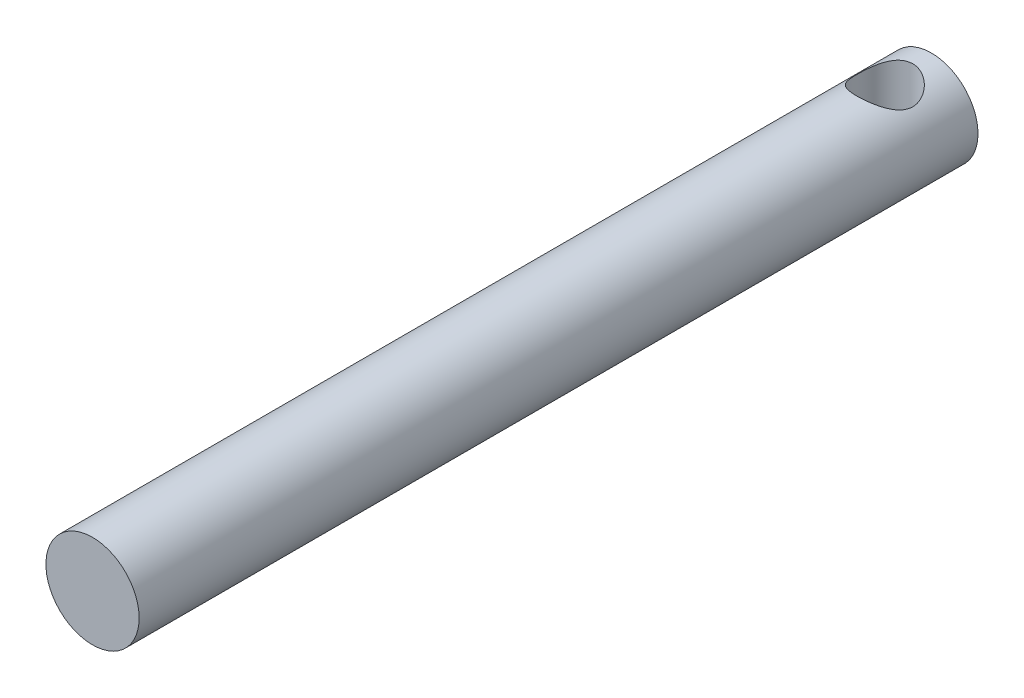
from build123d import *

# Parameters (mm, degrees)
SKETCH_1_R          = 10
EXTRUDE_1_DEPTH     = 180
SKETCH_2_R          = 6
CUT_EXTRUDE_2_DEPTH = 97


with BuildPart() as part:
    # 草图1 → 凸台-拉伸1 (new body)
    with BuildSketch(Plane.XY):
        with Locations((-13.509190135, 11.410675163)):
            Circle(SKETCH_1_R)
    extrude(amount=EXTRUDE_1_DEPTH)

    # 草图2 → 切除-拉伸2 (cut)
    with BuildSketch(Plane(origin=(0, 0, 0), x_dir=(1, 0, 0), z_dir=(0, 1, 0))):
        with Locations((-13.509190135, -10)):
            Circle(SKETCH_2_R)
    extrude(amount=CUT_EXTRUDE_2_DEPTH, mode=Mode.SUBTRACT)


solid = part.part
